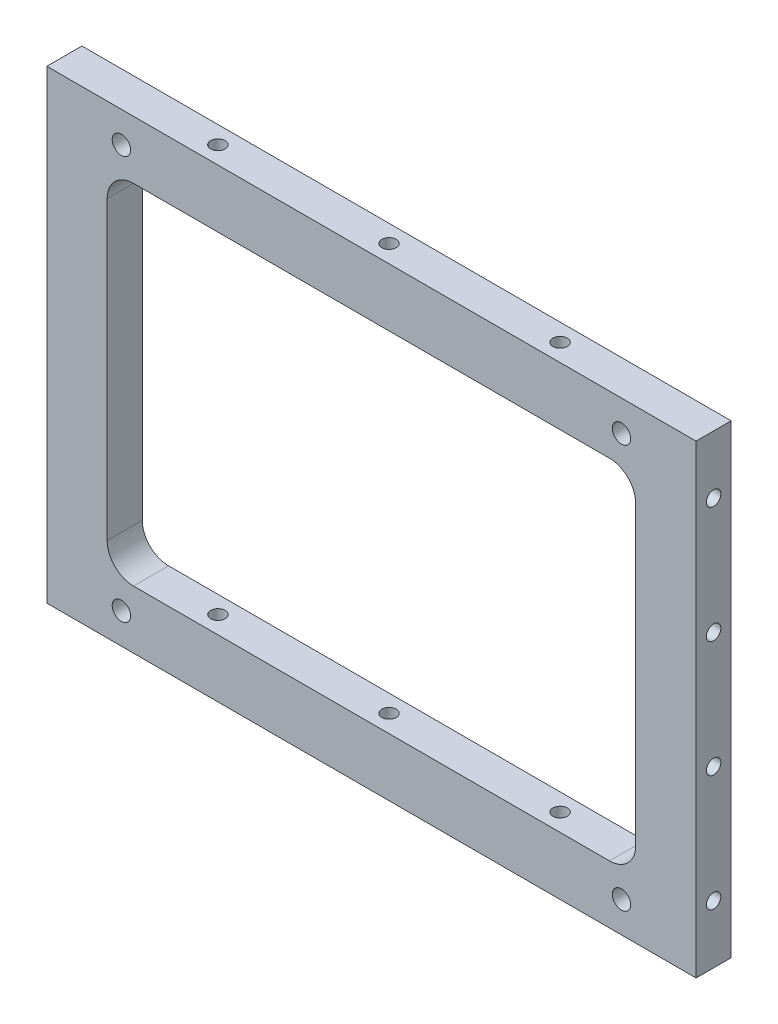
from build123d import *

# Parameters (mm, degrees)
SKETCH1_W           = 148
SKETCH1_H           = 106
BOSS_EXTRUDE1_DEPTH = 8
CUT_EXTRUDE1_REACH  = 93.373
SKETCH2_R           = 2.1
SKETCH3_R           = 1.65
CUT_EXTRUDE2_DEPTH  = 130.52219887
SKETCH5_R           = 1.65
CUT_EXTRUDE3_DEPTH  = 10
CUT_EXTRUDE4_START  = -10
SKETCH6_R           = 1.65
CUT_EXTRUDE4_DEPTH  = 10


with BuildPart() as part:
    # Sketch1 → Boss-Extrude1 (new body)
    with BuildSketch(Plane.XY):
        Rectangle(SKETCH1_W, SKETCH1_H)
    extrude(amount=-BOSS_EXTRUDE1_DEPTH)

    # Sketch2 → Cut-Extrude1 (cut, up to next)
    with BuildSketch(Plane.XY, mode=Mode.PRIVATE) as cut_extrude1_sk1:
        with Locations((-57, 46)):
            Circle(SKETCH2_R)
    cut_extrude1_tool1 = extrude(cut_extrude1_sk1.sketch, amount=-CUT_EXTRUDE1_REACH, mode=Mode.PRIVATE) & part.part
    # Sketch2 → Cut-Extrude1 (cut, up to next)
    with BuildSketch(Plane.XY, mode=Mode.PRIVATE) as cut_extrude1_sk2:
        with Locations((57, 46)):
            Circle(SKETCH2_R)
    cut_extrude1_tool2 = extrude(cut_extrude1_sk2.sketch, amount=-CUT_EXTRUDE1_REACH, mode=Mode.PRIVATE) & part.part
    # Sketch2 → Cut-Extrude1 (cut, up to next)
    with BuildSketch(Plane.XY, mode=Mode.PRIVATE) as cut_extrude1_sk3:
        with BuildLine():
            ThreePointArc((-54.25, 39.75), (-58.492640687, 37.992640687), (-60.25, 33.75))
            Line((-60.25, 33.75), (-60.25, -33.75))
            ThreePointArc((-60.25, -33.75), (-58.492640687, -37.992640687), (-54.25, -39.75))
            Line((-54.25, -39.75), (54.25, -39.75))
            ThreePointArc((54.25, -39.75), (58.492640687, -37.992640687), (60.25, -33.75))
            Line((60.25, -33.75), (60.25, 33.75))
            ThreePointArc((60.25, 33.75), (58.492640687, 37.992640687), (54.25, 39.75))
            Line((54.25, 39.75), (-54.25, 39.75))
        make_face()
    cut_extrude1_tool3 = extrude(cut_extrude1_sk3.sketch, amount=-CUT_EXTRUDE1_REACH, mode=Mode.PRIVATE) & part.part
    # Sketch2 → Cut-Extrude1 (cut, up to next)
    with BuildSketch(Plane.XY, mode=Mode.PRIVATE) as cut_extrude1_sk4:
        with Locations((-57, -46)):
            Circle(SKETCH2_R)
    cut_extrude1_tool4 = extrude(cut_extrude1_sk4.sketch, amount=-CUT_EXTRUDE1_REACH, mode=Mode.PRIVATE) & part.part
    # Sketch2 → Cut-Extrude1 (cut, up to next)
    with BuildSketch(Plane.XY, mode=Mode.PRIVATE) as cut_extrude1_sk5:
        with Locations((57, -46)):
            Circle(SKETCH2_R)
    cut_extrude1_tool5 = extrude(cut_extrude1_sk5.sketch, amount=-CUT_EXTRUDE1_REACH, mode=Mode.PRIVATE) & part.part
    add(cut_extrude1_tool1.solids().sort_by_distance((-57, 46, 0))[0], mode=Mode.SUBTRACT)
    add(cut_extrude1_tool2.solids().sort_by_distance((57, 46, 0))[0], mode=Mode.SUBTRACT)
    add(cut_extrude1_tool3.solids().sort_by_distance((0, 0, 0))[0], mode=Mode.SUBTRACT)
    add(cut_extrude1_tool4.solids().sort_by_distance((-57, -46, 0))[0], mode=Mode.SUBTRACT)
    add(cut_extrude1_tool5.solids().sort_by_distance((57, -46, 0))[0], mode=Mode.SUBTRACT)

    # Sketch3 → Cut-Extrude2 (cut, through all)
    with BuildSketch(Plane.XZ.offset(53)):
        with Locations((-39, -4)):
            Circle(SKETCH3_R)
        with Locations((0, -4)):
            Circle(SKETCH3_R)
        with Locations((39, -4)):
            Circle(SKETCH3_R)
    extrude(amount=-CUT_EXTRUDE2_DEPTH, mode=Mode.SUBTRACT)

    # Sketch5 → Cut-Extrude3 (cut)
    with BuildSketch(Plane(origin=(74, 0, 0), x_dir=(0, 0, -1), z_dir=(1, 0, 0))):
        with Locations((4, 39.75)):
            Circle(SKETCH5_R)
        with Locations((4, 13.25)):
            Circle(SKETCH5_R)
        with Locations((4, -13.25)):
            Circle(SKETCH5_R)
        with Locations((4, -39.75)):
            Circle(SKETCH5_R)
    extrude(amount=-CUT_EXTRUDE3_DEPTH, mode=Mode.SUBTRACT)

    # Sketch6 → Cut-Extrude4 (cut)
    with BuildSketch(Plane.ZY.offset(74).offset(CUT_EXTRUDE4_START)):
        with Locations((-4, 39.75)):
            Circle(SKETCH6_R)
        with Locations((-4, 13.25)):
            Circle(SKETCH6_R)
        with Locations((-4, -13.25)):
            Circle(SKETCH6_R)
        with Locations((-4, -39.75)):
            Circle(SKETCH6_R)
    extrude(amount=CUT_EXTRUDE4_DEPTH, mode=Mode.SUBTRACT)


solid = part.part
